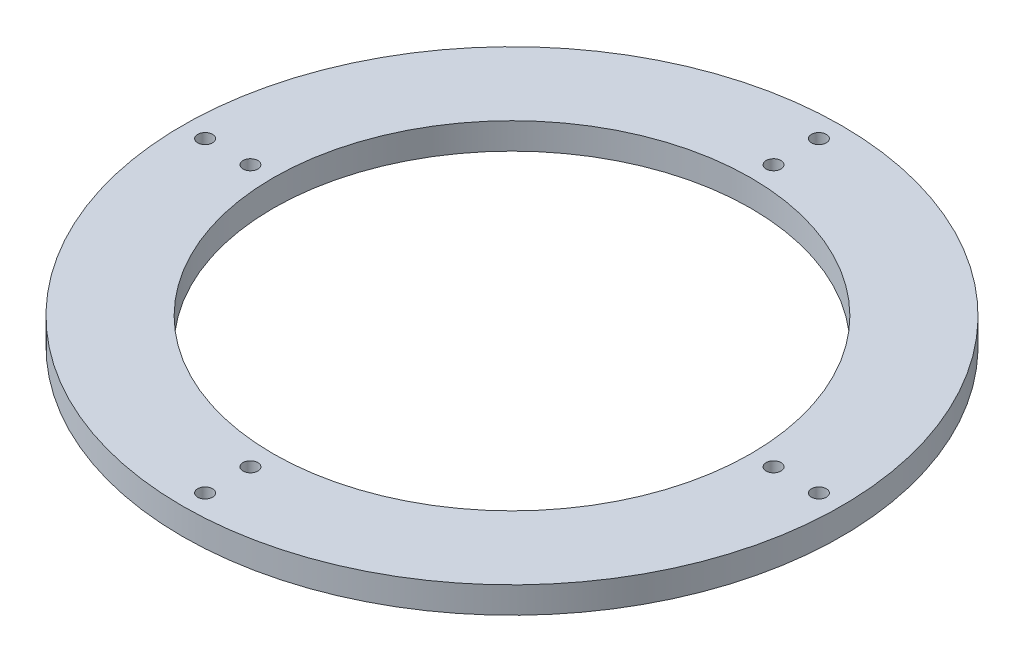
from build123d import *

# Parameters (mm, degrees)
SKETCH1_R           = 100
SKETCH1_R_2         = 72.5
BOSS_EXTRUDE1_DEPTH = 8
SKETCH2_R           = 2.25
CUT_EXTRUDE1_DEPTH  = 8


with BuildPart() as part:
    # Sketch1 → Boss-Extrude1 (new body)
    with BuildSketch(Plane(origin=(0, 0, 0), x_dir=(1, 0, 0), z_dir=(0, 1, 0))):
        Circle(SKETCH1_R)
        Circle(SKETCH1_R_2, mode=Mode.SUBTRACT)
    extrude(amount=BOSS_EXTRUDE1_DEPTH)

    # Sketch2 → Cut-Extrude1 (cut)
    with BuildSketch(Plane(origin=(0, 0, 0), x_dir=(1, 0, 0), z_dir=(0, 1, 0))):
        with Locations((0, 93.125)):
            Circle(SKETCH2_R)
        with Locations((93.125, 0)):
            Circle(SKETCH2_R)
        with Locations((0, -93.125)):
            Circle(SKETCH2_R)
        with Locations((-93.125, 0)):
            Circle(SKETCH2_R)
        with Locations((0, 79.375)):
            Circle(SKETCH2_R)
        with Locations((79.375, 0)):
            Circle(SKETCH2_R)
        with Locations((0, -79.375)):
            Circle(SKETCH2_R)
        with Locations((-79.375, 0)):
            Circle(SKETCH2_R)
    extrude(amount=CUT_EXTRUDE1_DEPTH, mode=Mode.SUBTRACT)


solid = part.part
